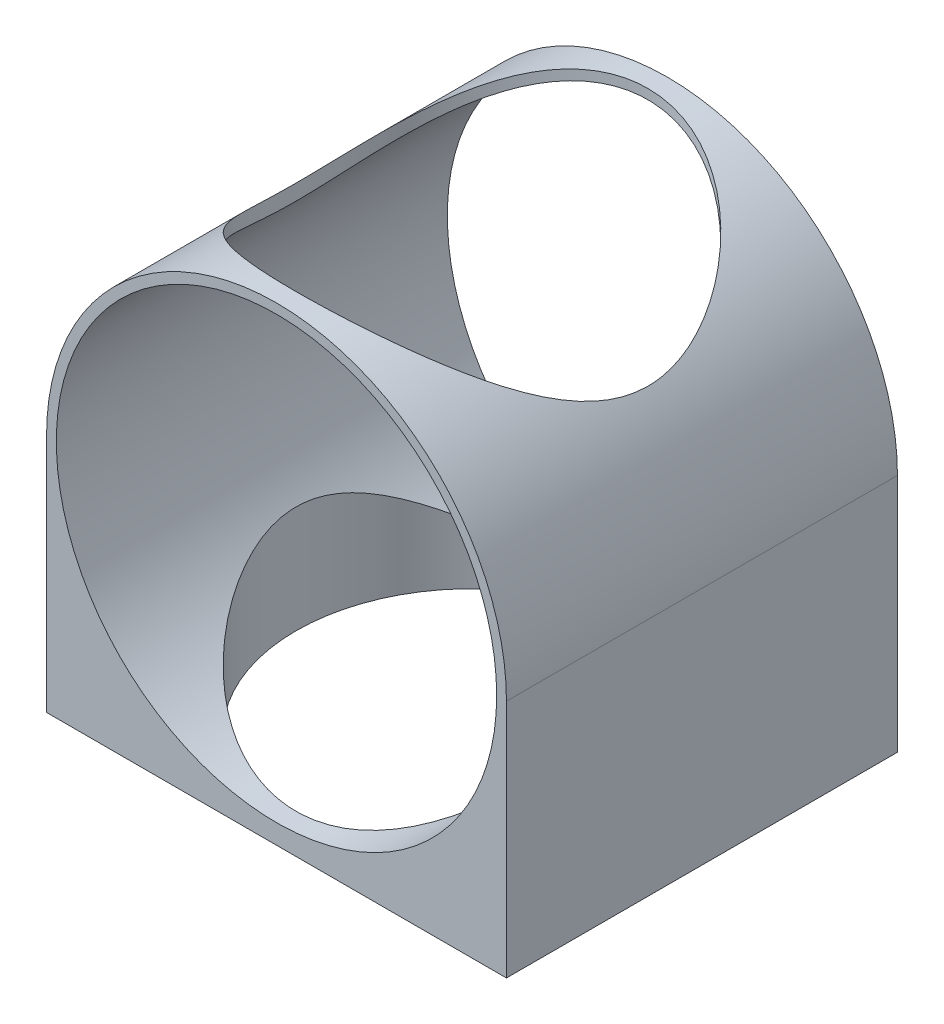
from build123d import *

# Parameters (mm, degrees)
BOSS_EXTRUDE1_START = -352.453482
SKETCH1_R           = 23.525
SKETCH1_R_2         = 22.525
BOSS_EXTRUDE1_DEPTH = 20
BOSS_EXTRUDE2_DEPTH = 40
SKETCH3_R           = 18
CUT_EXTRUDE1_DEPTH  = 74.525


with BuildPart() as part:
    # Sketch1 → Boss-Extrude1 (new body, symmetric)
    with BuildSketch(Plane.XY.offset(BOSS_EXTRUDE1_START)):
        Circle(SKETCH1_R)
        Circle(SKETCH1_R_2, mode=Mode.SUBTRACT)
    extrude(amount=BOSS_EXTRUDE1_DEPTH, both=True)

    # Sketch4 → Boss-Extrude2 (add)
    with BuildSketch(Plane.XY.offset(-332.453482287)):
        Polygon((23.525, -23.525), (23.525, -24.525), (-23.525, -24.525), (-23.525, -23.525), (0, -23.525), align=None)
        with BuildLine():
            ThreePointArc((0, -23.525), (-16.634687027, -16.634687027), (-23.525, 0))
            Line((-23.525, 0), (-23.525, -23.525))
            Line((-23.525, -23.525), (0, -23.525))
        make_face()
        with BuildLine():
            Line((23.525, -23.525), (23.525, 0))
            ThreePointArc((23.525, 0), (16.634687027, -16.634687027), (0, -23.525))
            Line((0, -23.525), (23.525, -23.525))
        make_face()
    extrude(amount=-BOSS_EXTRUDE2_DEPTH)

    # Sketch3 → Cut-Extrude1 (cut, through all)
    with BuildSketch(Plane.XZ.offset(50)):
        with Locations((0, -352.453482287)):
            Circle(SKETCH3_R)
    extrude(amount=-CUT_EXTRUDE1_DEPTH, mode=Mode.SUBTRACT)


solid = part.part
